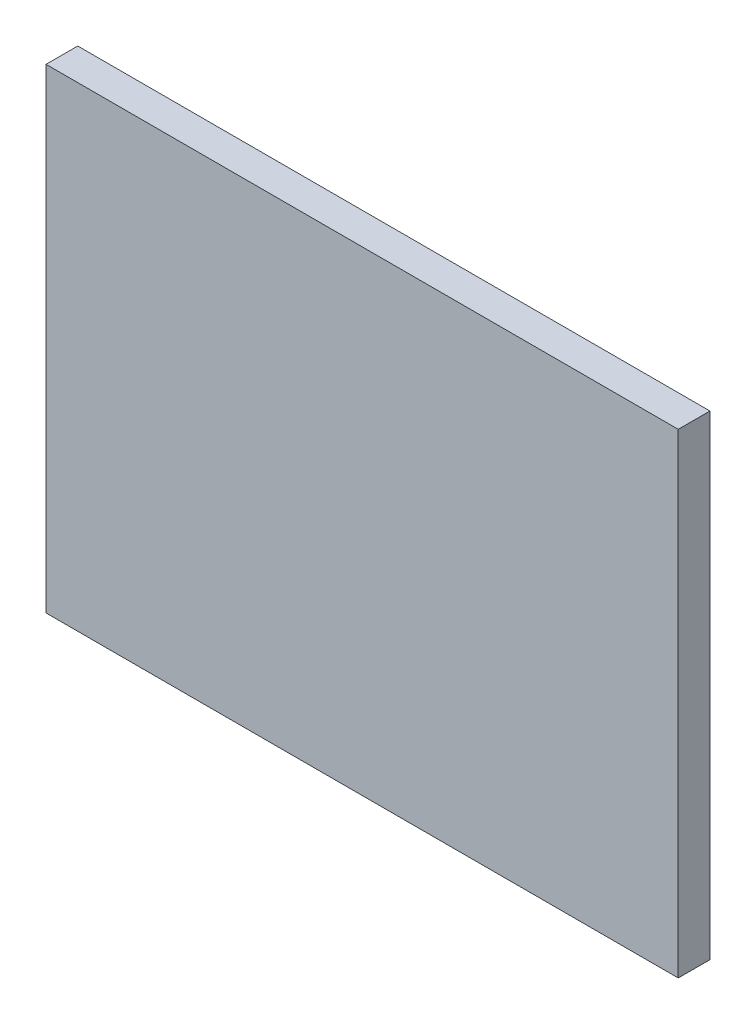
from build123d import *

# Parameters (mm, degrees)
ESQUISSE1_W        = 117.65
ESQUISSE1_H        = 88.43
BOSS_EXTRU_1_DEPTH = 5.9


with BuildPart() as part:
    # Esquisse1 → Boss.-Extru.1 (new body)
    with BuildSketch(Plane.XY):
        with Locations((58.825, 44.215)):
            Rectangle(ESQUISSE1_W, ESQUISSE1_H)
    extrude(amount=BOSS_EXTRU_1_DEPTH)


solid = part.part
